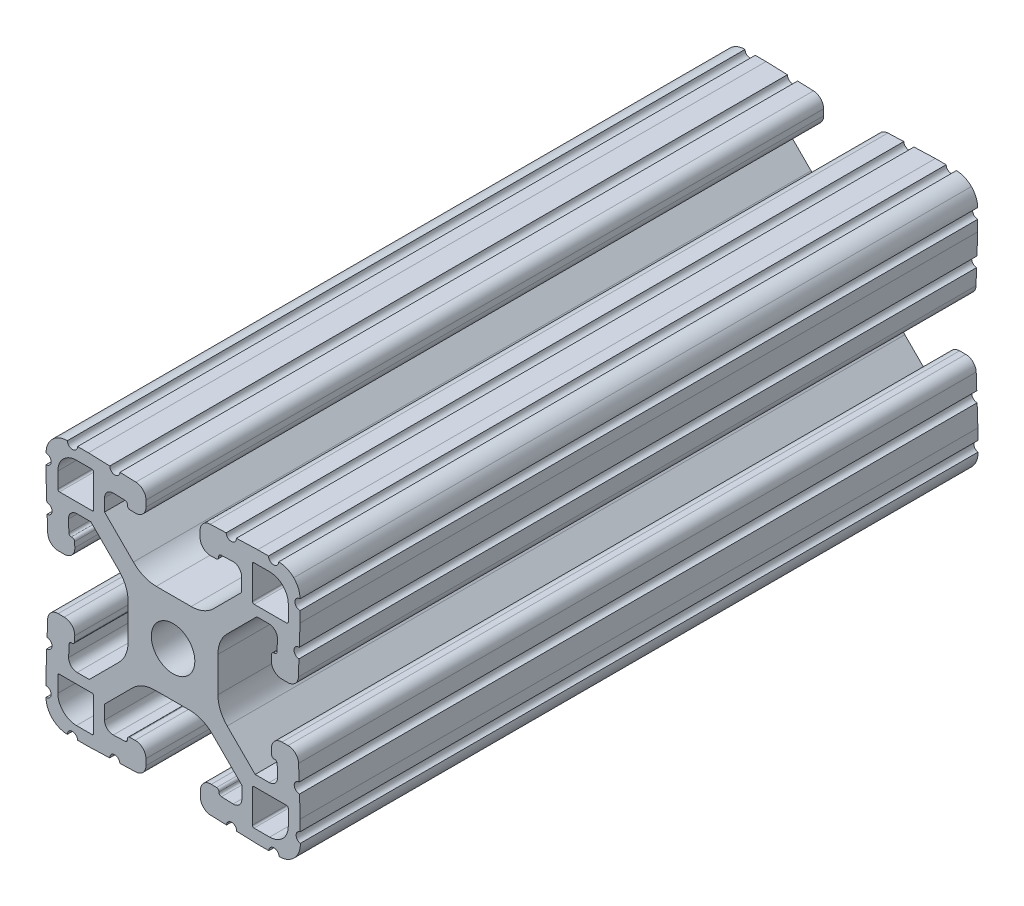
from build123d import *

# Parameters (mm, degrees)
SKETCH1_R           = 3.2639
BOSS_EXTRUDE1_DEPTH = 101.6


with BuildPart() as part:
    # Sketch1 → Boss-Extrude1 (new body)
    with BuildSketch(Plane(origin=(0, 0, -25.4), x_dir=(-1, 0, 0), z_dir=(0, 0, -1))):
        with BuildLine():
            Line((-88.043721549, 91.862643967), (-86.29674679, 91.923648859))
            ThreePointArc((-86.29674679, 91.923648859), (-85.370208675, 91.567983831), (-84.982425017, 90.654422489))
            Line((-84.982425017, 90.654422489), (-84.982425017, 88.800173916))
            Line((-84.982425017, 88.800173916), (-89.306565884, 84.476033049))
            ThreePointArc((-89.306565884, 84.476033049), (-90.866149908, 83.406077005), (-92.719610366, 83.029523439))
            Line((-92.719610366, 83.029523439), (-97.961628589, 83.029523439))
            ThreePointArc((-97.961628589, 83.029523439), (-99.779298356, 83.391080435), (-101.320244378, 84.42070765))
            Line((-101.320244378, 84.42070765), (-105.516001761, 88.616465033))
            Line((-105.516001761, 88.616465033), (-105.516001761, 90.731330035))
            ThreePointArc((-105.516001761, 90.731330035), (-105.128218103, 91.644891377), (-104.201679988, 92.000556406))
            Line((-104.201679988, 92.000556406), (-102.454705229, 91.939551513))
            ThreePointArc((-102.454705229, 91.939551513), (-102.193933359, 91.823448504), (-102.087001761, 91.558783602))
            ThreePointArc((-102.087001761, 91.558783602), (-102.010859042, 91.249291513), (-101.726191901, 91.105946874))
            Line((-101.726191901, 91.105946874), (-100.929727576, 91.078102142))
            ThreePointArc((-100.929727576, 91.078102142), (-99.780779944, 91.519102656), (-99.299905511, 92.651940638))
            Line((-99.299905511, 92.651940638), (-99.299905511, 93.566848638))
            ThreePointArc((-99.299905511, 93.566848638), (-99.741889517, 94.660796975), (-100.819746715, 95.140689345))
            Line((-100.819746715, 95.140689345), (-103.211918901, 95.224224422))
            ThreePointArc((-103.211918901, 95.224224422), (-104.000045777, 94.489281495), (-104.734990687, 95.277406522))
            Line((-104.734990687, 95.277406522), (-107.935905676, 95.389166912))
            Line((-107.935905676, 95.389166912), (-109.561454876, 95.389166912))
            ThreePointArc((-109.561454876, 95.389166912), (-110.323454876, 94.627166912), (-111.085454876, 95.389166912))
            ThreePointArc((-111.085454876, 95.389166912), (-112.308767787, 95.144035599), (-113.343184761, 94.446493225))
            ThreePointArc((-113.343184761, 94.446493225), (-114.04072548, 93.412075135), (-114.285854836, 92.188761832))
            ThreePointArc((-114.285854836, 92.188761832), (-113.523853616, 91.426762441), (-114.285853616, 90.664761832))
            Line((-114.285853616, 90.664761832), (-114.285853616, 89.039212632))
            Line((-114.285853616, 89.039212632), (-114.174093219, 85.838297643))
            ThreePointArc((-114.174093219, 85.838297643), (-113.385968191, 85.103352735), (-114.120911115, 84.315225857))
            Line((-114.120911115, 84.315225857), (-114.037376031, 81.923053667))
            ThreePointArc((-114.037376031, 81.923053667), (-113.55748366, 80.845196472), (-112.463535325, 80.403212468))
            Line((-112.463535325, 80.403212468), (-111.548627325, 80.403212468))
            ThreePointArc((-111.548627325, 80.403212468), (-110.415788905, 80.884087354), (-109.974788872, 82.033035791))
            Line((-109.974788872, 82.033035791), (-110.002634241, 82.829500094))
            ThreePointArc((-110.002634241, 82.829500094), (-110.118742417, 83.090261917), (-110.383401914, 83.197188))
            ThreePointArc((-110.383401914, 83.197188), (-110.693757401, 83.272605688), (-110.837665276, 83.557735272))
            Line((-110.837665276, 83.557735272), (-110.898671566, 85.304709982))
            ThreePointArc((-110.898671566, 85.304709982), (-110.543006925, 86.231248747), (-109.62944523, 86.61903277))
            Line((-109.62944523, 86.61903277), (-107.807161806, 86.61903277))
            Line((-107.807161806, 86.61903277), (-103.364925613, 82.176810793))
            ThreePointArc((-103.364925613, 82.176810793), (-102.335294479, 80.635862907), (-101.973736029, 78.81818963))
            Line((-101.973736029, 78.81818963), (-101.973736029, 73.576034207))
            ThreePointArc((-101.973736029, 73.576034207), (-102.335293752, 71.758362684), (-103.364922926, 70.21741573))
            Line((-103.364922926, 70.21741573), (-107.560683666, 66.021661704))
            Line((-107.560683666, 66.021661704), (-109.652436558, 66.021661704))
            ThreePointArc((-109.652436558, 66.021661704), (-110.565998503, 66.409445617), (-110.921663765, 67.335984343))
            Line((-110.921663765, 67.335984343), (-110.860658873, 69.082959102))
            ThreePointArc((-110.860658873, 69.082959102), (-110.744555864, 69.343730973), (-110.479890961, 69.45066257))
            ThreePointArc((-110.479890961, 69.45066257), (-110.173494703, 69.529390272), (-110.032185196, 69.812424443))
            Line((-110.032185196, 69.812424443), (-110.004340464, 70.608888768))
            ThreePointArc((-110.004340464, 70.608888768), (-110.445340978, 71.7578364), (-111.57817896, 72.238710833))
            Line((-111.57817896, 72.238710833), (-112.49308696, 72.238710833))
            ThreePointArc((-112.49308696, 72.238710833), (-113.587035297, 71.796726827), (-114.066927667, 70.718869629))
            Line((-114.066927667, 70.718869629), (-114.150462744, 68.326697443))
            ThreePointArc((-114.150462744, 68.326697443), (-113.415519817, 67.538570567), (-114.203644843, 66.803625657))
            Line((-114.203644843, 66.803625657), (-114.315405233, 63.602710668))
            Line((-114.315405233, 63.602710668), (-114.315405233, 61.962557497))
            ThreePointArc((-114.315405233, 61.962557497), (-113.701927281, 61.206106537), (-114.333208228, 60.464447842))
            ThreePointArc((-114.333208228, 60.464447842), (-114.113020459, 59.176546471), (-113.392816136, 58.086372941))
            ThreePointArc((-113.392816136, 58.086372941), (-112.358398046, 57.388832223), (-111.135084743, 57.143702867))
            ThreePointArc((-111.135084743, 57.143702867), (-110.373085352, 57.905704086), (-109.611084743, 57.143704086))
            Line((-109.611084743, 57.143704086), (-107.985535543, 57.143704086))
            Line((-107.985535543, 57.143704086), (-104.784620554, 57.255464483))
            ThreePointArc((-104.784620554, 57.255464483), (-104.049675645, 58.04358951), (-103.261548768, 57.308646586))
            Line((-103.261548768, 57.308646586), (-100.869376578, 57.39218167))
            ThreePointArc((-100.869376578, 57.39218167), (-99.791519383, 57.872074041), (-99.349535378, 58.966022376))
            Line((-99.349535378, 58.966022376), (-99.349535378, 59.880930376))
            ThreePointArc((-99.349535378, 59.880930376), (-99.830409811, 61.013768358), (-100.979357443, 61.454768873))
            Line((-100.979357443, 61.454768873), (-101.775821768, 61.42692414))
            ThreePointArc((-101.775821768, 61.42692414), (-102.036583684, 61.310816174), (-102.143509978, 61.046156762))
            ThreePointArc((-102.143509978, 61.046156762), (-102.222494916, 60.740061862), (-102.505377386, 60.598958297))
            Line((-102.505377386, 60.598958297), (-104.252352145, 60.537953405))
            ThreePointArc((-104.252352145, 60.537953405), (-105.17889026, 60.893618433), (-105.566673918, 61.807179775))
            Line((-105.566673918, 61.807179775), (-105.566673918, 63.629462758))
            Line((-105.566673918, 63.629462758), (-101.131142468, 68.064994208))
            ThreePointArc((-101.131142468, 68.064994208), (-99.590196446, 69.094621422), (-97.772526678, 69.456178419))
            Line((-97.772526678, 69.456178419), (-92.530356056, 69.456178419))
            ThreePointArc((-92.530356056, 69.456178419), (-90.712686289, 69.094621422), (-89.171740267, 68.064994208))
            Line((-89.171740267, 68.064994208), (-84.975982884, 63.869236825))
            Line((-84.975982884, 63.869236825), (-84.975982884, 61.781050107))
            ThreePointArc((-84.975982884, 61.781050107), (-85.363766542, 60.867488765), (-86.290304657, 60.511823736))
            Line((-86.290304657, 60.511823736), (-88.037279416, 60.572828629))
            ThreePointArc((-88.037279416, 60.572828629), (-88.298051286, 60.688931638), (-88.404982884, 60.95359654))
            ThreePointArc((-88.404982884, 60.95359654), (-88.466593694, 61.278962759), (-88.759626911, 61.433204782))
            Line((-88.759626911, 61.433204782), (-89.556091237, 61.461049514))
            ThreePointArc((-89.556091237, 61.461049514), (-90.705038868, 61.020049), (-91.185913301, 59.887211018))
            Line((-91.185913301, 59.887211018), (-91.185913301, 58.972303018))
            ThreePointArc((-91.185913301, 58.972303018), (-90.743929295, 57.878354681), (-89.666072098, 57.398462311))
            Line((-89.666072098, 57.398462311), (-87.273899911, 57.314927234))
            ThreePointArc((-87.273899911, 57.314927234), (-86.485773036, 58.049870161), (-85.750828126, 57.261745135))
            Line((-85.750828126, 57.261745135), (-82.549913136, 57.149984745))
            Line((-82.549913136, 57.149984745), (-80.924363936, 57.149984745))
            ThreePointArc((-80.924363936, 57.149984745), (-80.162363936, 57.911984745), (-79.400363936, 57.149984745))
            ThreePointArc((-79.400363936, 57.149984745), (-78.177051025, 57.395116058), (-77.142634052, 58.092658432))
            ThreePointArc((-77.142634052, 58.092658432), (-76.445094372, 59.127074031), (-76.199963977, 60.350384428))
            ThreePointArc((-76.199963977, 60.350384428), (-76.961961268, 61.112385783), (-76.199961268, 61.874384428))
            Line((-76.199961268, 61.874384428), (-76.199961268, 63.499933628))
            Line((-76.199961268, 63.499933628), (-76.311721666, 66.700848617))
            ThreePointArc((-76.311721666, 66.700848617), (-77.099846694, 67.435793525), (-76.364903769, 68.223920403))
            Line((-76.364903769, 68.223920403), (-76.448438853, 70.616092593))
            ThreePointArc((-76.448438853, 70.616092593), (-76.928331225, 71.693949788), (-78.02227956, 72.135933792))
            Line((-78.02227956, 72.135933792), (-78.93718756, 72.135933792))
            ThreePointArc((-78.93718756, 72.135933792), (-80.07002598, 71.655058906), (-80.511026012, 70.506110469))
            Line((-80.511026012, 70.506110469), (-80.483180643, 69.709646166))
            ThreePointArc((-80.483180643, 69.709646166), (-80.367072468, 69.448884343), (-80.102412971, 69.34195826))
            ThreePointArc((-80.102412971, 69.34195826), (-79.796317908, 69.262973649), (-79.655214052, 68.980091239))
            Line((-79.655214052, 68.980091239), (-79.594207761, 67.233116529))
            ThreePointArc((-79.594207761, 67.233116529), (-79.949872402, 66.306577764), (-80.863434097, 65.918793741))
            Line((-80.863434097, 65.918793741), (-82.685717521, 65.918793741))
            Line((-82.685717521, 65.918793741), (-87.121258001, 70.35431293))
            ThreePointArc((-87.121258001, 70.35431293), (-88.150863946, 71.895196205), (-88.512450271, 73.712794894))
            Line((-88.512450271, 73.712794894), (-88.512606864, 78.954950317))
            ThreePointArc((-88.512606864, 78.954950317), (-88.151076291, 80.772698182), (-87.121419968, 82.313710679))
            Line((-87.121419968, 82.313710679), (-82.925659228, 86.509464706))
            Line((-82.925659228, 86.509464706), (-80.837473527, 86.509464706))
            ThreePointArc((-80.837473527, 86.509464706), (-79.923911584, 86.121680793), (-79.568246321, 85.195142068))
            Line((-79.568246321, 85.195142068), (-79.629251214, 83.448167309))
            ThreePointArc((-79.629251214, 83.448167309), (-79.745354223, 83.187395438), (-80.010019125, 83.080463841))
            ThreePointArc((-80.010019125, 83.080463841), (-80.335385344, 83.018853031), (-80.489627367, 82.725819813))
            Line((-80.489627367, 82.725819813), (-80.5174721, 81.929355488))
            ThreePointArc((-80.5174721, 81.929355488), (-80.076471586, 80.780407856), (-78.943633603, 80.299533423))
            Line((-78.943633603, 80.299533423), (-78.028725603, 80.299533423))
            ThreePointArc((-78.028725603, 80.299533423), (-76.934777267, 80.741517429), (-76.454884897, 81.819374627))
            Line((-76.454884897, 81.819374627), (-76.37134982, 84.211546813))
            ThreePointArc((-76.37134982, 84.211546813), (-77.106292747, 84.999673689), (-76.31816772, 85.734618599))
            Line((-76.31816772, 85.734618599), (-76.20640733, 88.935533588))
            Line((-76.20640733, 88.935533588), (-76.20640733, 90.561082788))
            ThreePointArc((-76.20640733, 90.561082788), (-76.96840733, 91.323083398), (-76.206406111, 92.085082788))
            ThreePointArc((-76.206406111, 92.085082788), (-76.451535467, 93.308396091), (-77.149076185, 94.342814181))
            ThreePointArc((-77.149076185, 94.342814181), (-78.183493159, 95.040356555), (-79.40680607, 95.285487868))
            ThreePointArc((-79.40680607, 95.285487868), (-80.16880607, 94.523487868), (-80.93080607, 95.285487868))
            Line((-80.93080607, 95.285487868), (-82.55635527, 95.285487868))
            Line((-82.55635527, 95.285487868), (-85.757270259, 95.173727471))
            ThreePointArc((-85.757270259, 95.173727471), (-86.492215168, 94.385602444), (-87.280342045, 95.120545368))
            Line((-87.280342045, 95.120545368), (-89.672514235, 95.037010285))
            ThreePointArc((-89.672514235, 95.037010285), (-90.75037143, 94.557117913), (-91.192355435, 93.463169578))
            Line((-91.192355435, 93.463169578), (-91.192355435, 92.548261578))
            ThreePointArc((-91.192355435, 92.548261578), (-90.711481002, 91.415423596), (-89.56253337, 90.974423082))
            Line((-89.56253337, 90.974423082), (-88.766069045, 91.002267814))
            ThreePointArc((-88.766069045, 91.002267814), (-88.505307129, 91.11837578), (-88.398380835, 91.383035192))
            ThreePointArc((-88.398380835, 91.383035192), (-88.336765486, 91.708407548), (-88.043721549, 91.862643967))
        make_face()
        with Locations(Location((-95.25, 76.2, 0), (0, 0, 180))):  # turned: the seam where the file's is
            Circle(SKETCH1_R, mode=Mode.SUBTRACT)
        with BuildLine():
            Line((-83.357745393, 88.294108398), (-83.357745393, 93.170908398))
            ThreePointArc((-83.357745393, 93.170908398), (-83.283351492, 93.350512545), (-83.103748154, 93.424908398))
            Line((-83.103748154, 93.424908398), (-80.766975763, 93.424933798))
            ThreePointArc((-80.766975763, 93.424933798), (-78.791299784, 92.606600882), (-77.972945393, 90.630933798))
            Line((-77.972945393, 90.630933798), (-77.972945393, 88.294108398))
            ThreePointArc((-77.972945393, 88.294108398), (-78.047340271, 88.114503276), (-78.226945393, 88.040108398))
            Line((-78.226945393, 88.040108398), (-83.103745393, 88.040108398))
            ThreePointArc((-83.103745393, 88.040108398), (-83.283350516, 88.114503276), (-83.357745393, 88.294108398))
        make_face(mode=Mode.SUBTRACT)
        with BuildLine():
            Line((-83.357745393, 59.229091602), (-83.357745393, 64.105891602))
            ThreePointArc((-83.357745393, 64.105891602), (-83.283350516, 64.285496724), (-83.103745393, 64.359891602))
            Line((-83.103745393, 64.359891602), (-78.226945393, 64.359891602))
            ThreePointArc((-78.226945393, 64.359891602), (-78.047340271, 64.285496724), (-77.972945393, 64.105891602))
            Line((-77.972945393, 64.105891602), (-77.972945393, 61.769066202))
            ThreePointArc((-77.972945393, 61.769066202), (-78.791299784, 59.793399118), (-80.766975763, 58.975066202))
            Line((-80.766975763, 58.975066202), (-83.103748154, 58.975091602))
            ThreePointArc((-83.103748154, 58.975091602), (-83.283351492, 59.049487455), (-83.357745393, 59.229091602))
        make_face(mode=Mode.SUBTRACT)
        with BuildLine():
            Line((-107.142254607, 93.170908398), (-107.142254607, 88.294108398))
            ThreePointArc((-107.142254607, 88.294108398), (-107.216649484, 88.114503276), (-107.396254607, 88.040108398))
            Line((-107.396254607, 88.040108398), (-112.273054607, 88.040108398))
            ThreePointArc((-112.273054607, 88.040108398), (-112.452659729, 88.114503276), (-112.527054607, 88.294108398))
            Line((-112.527054607, 88.294108398), (-112.527054607, 90.630933798))
            ThreePointArc((-112.527054607, 90.630933798), (-111.708700216, 92.606600882), (-109.733024237, 93.424933798))
            Line((-109.733024237, 93.424933798), (-107.396251846, 93.424908398))
            ThreePointArc((-107.396251846, 93.424908398), (-107.216648508, 93.350512545), (-107.142254607, 93.170908398))
        make_face(mode=Mode.SUBTRACT)
        with BuildLine():
            Line((-107.142254607, 64.105891602), (-107.142254607, 59.229091602))
            ThreePointArc((-107.142254607, 59.229091602), (-107.216648508, 59.049487455), (-107.396251846, 58.975091602))
            Line((-107.396251846, 58.975091602), (-109.733024237, 58.975066202))
            ThreePointArc((-109.733024237, 58.975066202), (-111.708700216, 59.793399118), (-112.527054607, 61.769066202))
            Line((-112.527054607, 61.769066202), (-112.527054607, 64.105891602))
            ThreePointArc((-112.527054607, 64.105891602), (-112.452659729, 64.285496724), (-112.273054607, 64.359891602))
            Line((-112.273054607, 64.359891602), (-107.396254607, 64.359891602))
            ThreePointArc((-107.396254607, 64.359891602), (-107.216649484, 64.285496724), (-107.142254607, 64.105891602))
        make_face(mode=Mode.SUBTRACT)
    extrude(amount=-BOSS_EXTRUDE1_DEPTH)


solid = part.part
